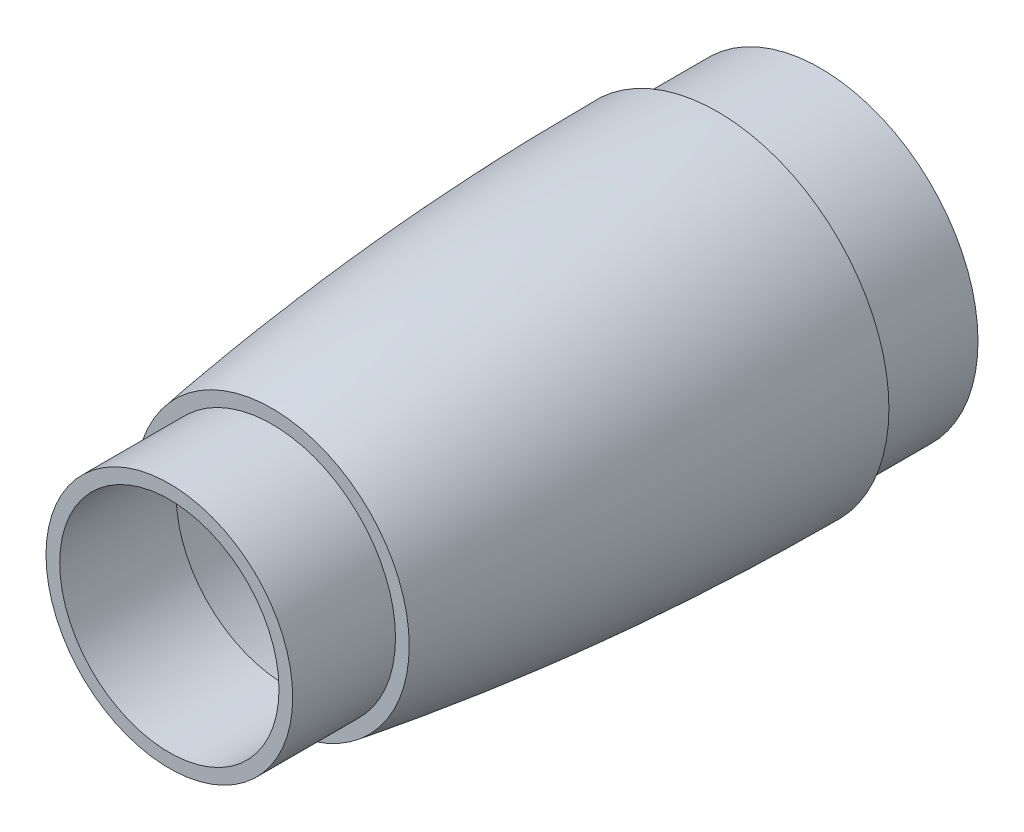
from build123d import *


with BuildPart() as part:
    # Sketch3 → Revolve1 (revolve)
    with BuildSketch(Plane(origin=(0, 0, 0), x_dir=(0, 0, -1), z_dir=(1, 0, 0)), mode=Mode.PRIVATE) as revolve1_sk:
        with BuildLine():
            Line((15, 19.999999997), (15, 17.999999997))
            Line((15, 17.999999997), (0, 17.999999997))
            Line((0, 17.999999997), (0, 15.999999997))
            Line((0, 15.999999997), (17, 15.999999997))
            Line((17, 15.999999997), (17, 18.282201438))
            add(Edge.make_bspline(
                [(17, 18.282201438), (22.070286152, 19.045867905), (32.256102656, 20.390541894), (47.498211654, 21.841802627), (62.751051161, 22.740030273), (72.915406547, 22.971232092), (77.999999854, 22.995272199)],
                knots=[0.104448986, 0.104448986, 0.104448986, 0.104448986, 0.301041309, 0.497633632, 0.694225955, 0.890818278, 0.890818278, 0.890818278, 0.890818278], degree=3))
            Line((77.999999854, 22.995272199), (77.999999854, 21))
            Line((77.999999854, 21), (94.999999854, 21))
            Line((94.999999854, 21), (94.999999854, 23))
            Line((94.999999854, 23), (79.999999854, 23))
            Line((79.999999854, 23), (79.999999854, 25))
            add(Edge.make_bspline(
                [(15, 19.999999997), (21.49999997, 21.005952567), (27.999999944, 21.89745556), (34.499999922, 22.675536927), (40.999999902, 23.341060186), (47.499999886, 23.8947337), (53.999999873, 24.337117594), (60.499999864, 24.668628723), (66.999999857, 24.889543884), (73.499999854, 25.000001318), (79.999999854, 25)],
                knots=[0.082609608, 0.082609608, 0.082609608, 0.082609608, 0.082609608, 0.082609608, 0.082609608, 0.082609608, 0.082609608, 0.082609608, 0.082609608, 0.916600873, 0.916600873, 0.916600873, 0.916600873, 0.916600873, 0.916600873, 0.916600873, 0.916600873, 0.916600873, 0.916600873, 0.916600873], degree=10))
        make_face()
    revolve(revolve1_sk.sketch.rotate(Axis((0, 0, 0), (0, 0, -1)), 90), axis=Axis((0, 0, 0), (0, 0, -1)))


solid = part.part
